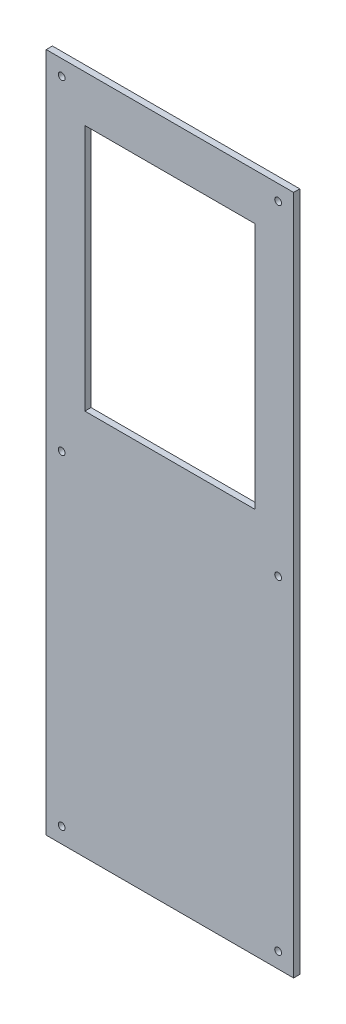
from build123d import *

# Parameters (mm, degrees)
ESQUISSE1_W        = 160
ESQUISSE1_H        = 440
ESQUISSE1_R        = 2.2
ESQUISSE1_W_2      = 110
ESQUISSE1_H_2      = 160
BOSS_EXTRU_1_DEPTH = 4


with BuildPart() as part:
    # Esquisse1 → Boss.-Extru.1 (new body)
    with BuildSketch(Plane.XY):
        Rectangle(ESQUISSE1_W, ESQUISSE1_H)
        with Locations((70, 0)):
            Circle(ESQUISSE1_R, mode=Mode.SUBTRACT)
        with Locations((70, 210)):
            Circle(ESQUISSE1_R, mode=Mode.SUBTRACT)
        with Locations((70, -210)):
            Circle(ESQUISSE1_R, mode=Mode.SUBTRACT)
        with Locations((-70, 210)):
            Circle(ESQUISSE1_R, mode=Mode.SUBTRACT)
        with Locations((-70, 0)):
            Circle(ESQUISSE1_R, mode=Mode.SUBTRACT)
        with Locations((-70, -210)):
            Circle(ESQUISSE1_R, mode=Mode.SUBTRACT)
        with Locations((0, 110)):
            Rectangle(ESQUISSE1_W_2, ESQUISSE1_H_2, mode=Mode.SUBTRACT)
    extrude(amount=BOSS_EXTRU_1_DEPTH)


solid = part.part
